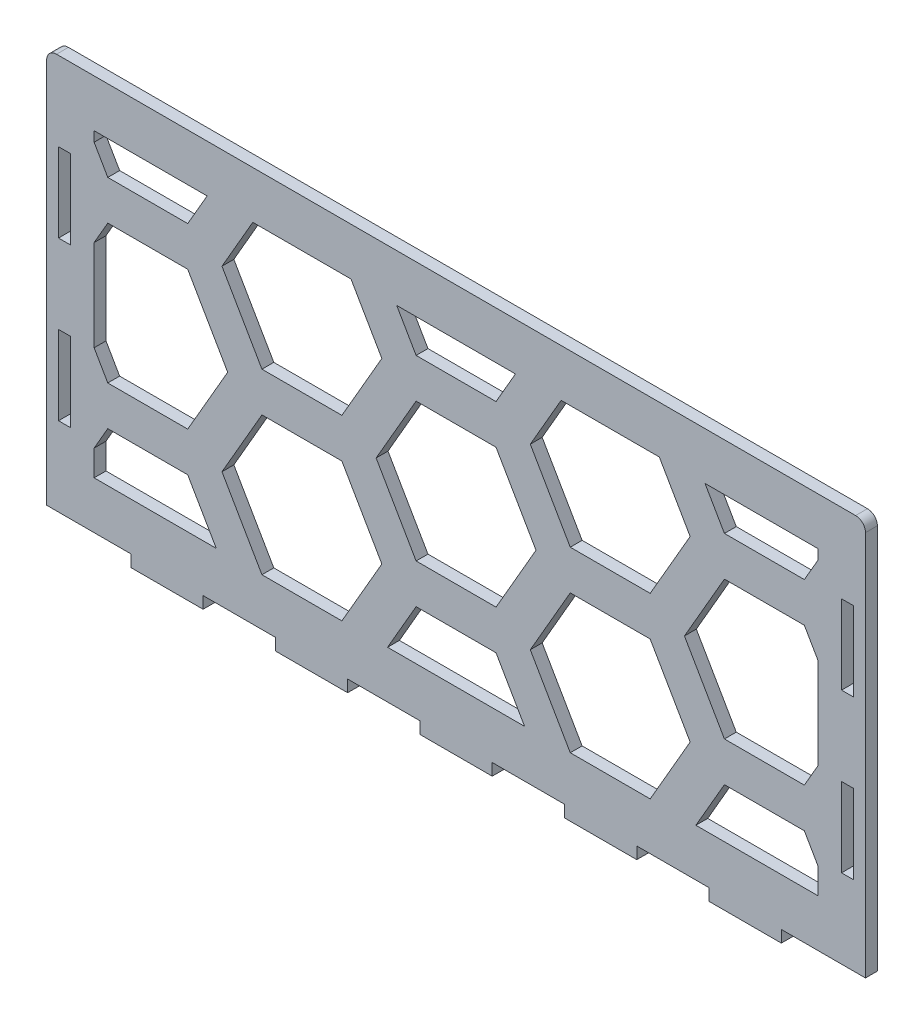
from build123d import *

# Parameters (mm, degrees)
SKETCH1_W               = 3.05
SKETCH1_H               = 20
SKETCH1_W_2             = 18.272727272
SKETCH1_H_2             = 3
SKETCH1_W_3             = 18.272727273
BOSS_EXTRUDE1_DEPTH     = 3
SKETCH5_W               = 207
SKETCH5_H               = 40
CUT_EXTRUDE7_DEPTH      = 1
CUT_EXTRUDE7_DEPTH_BACK = 4
FILLET3_R               = 2.5
CUT_EXTRUDE8_DEPTH      = 4
CUT_EXTRUDE8_DEPTH_BACK = 1


with BuildPart() as part:
    # Sketch1 → Boss-Extrude1 (new body)
    with BuildSketch(Plane.XY):
        Polygon((-103.5, 70), (-103.5, -70), (-82.227272727, -70), (-63.954545455, -70), (-45.681818182, -70), (-27.409090909, -70), (-9.136363636, -70), (9.136363636, -70), (27.409090909, -70), (45.681818182, -70), (63.954545455, -70), (82.227272727, -70), (103.5, -70), (103.5, 70), align=None)
        with Locations((-98.975, -40)):
            Rectangle(SKETCH1_W, SKETCH1_H, mode=Mode.SUBTRACT)
        with Locations((98.975, -40)):
            Rectangle(SKETCH1_W, SKETCH1_H, mode=Mode.SUBTRACT)
        with Locations((-98.975, 0)):
            Rectangle(SKETCH1_W, SKETCH1_H, mode=Mode.SUBTRACT)
        with Locations((-98.975, 40)):
            Rectangle(SKETCH1_W, SKETCH1_H, mode=Mode.SUBTRACT)
        with Locations((98.975, 0)):
            Rectangle(SKETCH1_W, SKETCH1_H, mode=Mode.SUBTRACT)
        with Locations((98.975, 40)):
            Rectangle(SKETCH1_W, SKETCH1_H, mode=Mode.SUBTRACT)
        with Locations((-73.090909091, -71.5)):
            Rectangle(SKETCH1_W_2, SKETCH1_H_2)
        with Locations((-36.545454546, -71.5)):
            Rectangle(SKETCH1_W_3, SKETCH1_H_2)
        with Locations((0, -71.5)):
            Rectangle(SKETCH1_W_2, SKETCH1_H_2)
        with Locations((36.545454546, -71.5)):
            Rectangle(SKETCH1_W_3, SKETCH1_H_2)
        with Locations((73.090909091, -71.5)):
            Rectangle(SKETCH1_W_2, SKETCH1_H_2)
    extrude(amount=BOSS_EXTRUDE1_DEPTH)

    # Sketch5 → Cut-Extrude7 (cut, two sides)
    with BuildSketch(Plane.XY.offset(3)) as cut_extrude7_sk:
        with Locations((0, 50)):
            Rectangle(SKETCH5_W, SKETCH5_H)
    extrude(amount=CUT_EXTRUDE7_DEPTH, mode=Mode.SUBTRACT)
    extrude(cut_extrude7_sk.sketch, amount=-CUT_EXTRUDE7_DEPTH_BACK, mode=Mode.SUBTRACT)

    # Fillet3
    fillet3_edges = [part.edges().sort_by_distance(p)[0] for p in [
        (103.5, 30, 1.5),
        (-103.5, 30, 1.5),
    ]]
    fillet(fillet3_edges, radius=FILLET3_R)

    # Sketch6 → Cut-Extrude8 (cut, two sides)
    with BuildSketch(Plane.XY) as cut_extrude8_sk:
        Polygon((-88.045916051, -0.5), (-91.5, -6.482648893), (-91.5, -29.517351107), (-88.045916051, -35.5), (-67.83865663, -35.5), (-57.735026919, -18), (-67.83865663, -0.5), align=None)
        Polygon((-62.931179342, 18), (-91.5, 18), (-91.5, 15.482648893), (-88.045916051, 9.5), (-67.83865663, 9.5), align=None)
        Polygon((-26.558112383, 18), (-51.384173958, 18), (-59.178402592, 4.5), (-49.074772881, -13), (-28.867513459, -13), (-18.763883749, 4.5), align=None)
        Polygon((10.103629711, -35.5), (20.207259422, -18), (10.103629711, -0.5), (-10.103629711, -0.5), (-20.207259422, -18), (-10.103629711, -35.5), align=None)
        Polygon((51.384173958, 18), (26.558112383, 18), (18.763883749, 4.5), (28.867513459, -13), (49.074772881, -13), (59.178402592, 4.5), align=None)
        Polygon((91.5, -29.517351107), (91.5, -6.482648893), (88.045916051, -0.5), (67.83865663, -0.5), (57.735026919, -18), (67.83865663, -35.5), (88.045916051, -35.5), align=None)
        Polygon((91.5, 15.482648893), (91.5, 18), (62.931179342, 18), (67.83865663, 9.5), (88.045916051, 9.5), align=None)
        Polygon((15.011106999, 18), (-15.011106999, 18), (-10.103629711, 9.5), (10.103629711, 9.5), align=None)
        Polygon((-28.867513459, -23), (-49.074772881, -23), (-59.178402592, -40.5), (-49.074772881, -58), (-28.867513459, -58), (-18.763883749, -40.5), align=None)
        Polygon((-88.045916051, -45.5), (-91.5, -51.482648893), (-91.5, -58), (-60.621778265, -58), (-67.83865663, -45.5), align=None)
        Polygon((-10.103629711, -45.5), (-17.320508076, -58), (17.320508076, -58), (10.103629711, -45.5), align=None)
        Polygon((49.074772881, -23), (28.867513459, -23), (18.763883749, -40.5), (28.867513459, -58), (49.074772881, -58), (59.178402592, -40.5), align=None)
        Polygon((91.5, -58), (91.5, -51.482648893), (88.045916051, -45.5), (67.83865663, -45.5), (60.621778265, -58), align=None)
    extrude(amount=CUT_EXTRUDE8_DEPTH, mode=Mode.SUBTRACT)
    extrude(cut_extrude8_sk.sketch, amount=-CUT_EXTRUDE8_DEPTH_BACK, mode=Mode.SUBTRACT)


solid = part.part
